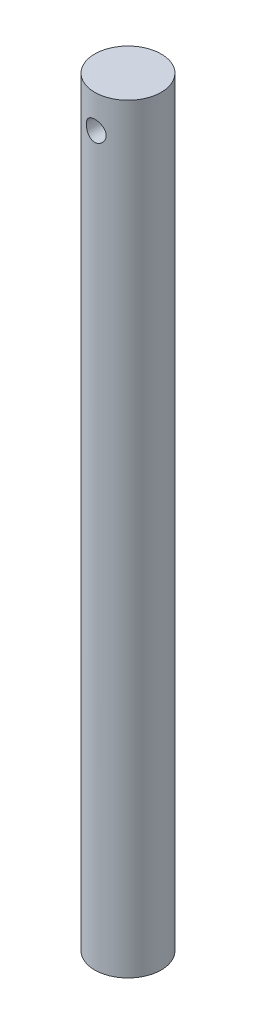
from build123d import *

# Parameters (mm, degrees)
SKETCH1_R               = 9.9949
BOSS_EXTRUDE1_DEPTH     = 228.6
SKETCH2_R               = 2.9972
CUT_EXTRUDE1_DEPTH      = 10.9949
CUT_EXTRUDE1_DEPTH_BACK = 10.9949


with BuildPart() as part:
    # Sketch1 → Boss-Extrude1 (new body)
    with BuildSketch(Plane(origin=(0, 0, 0), x_dir=(1, 0, 0), z_dir=(0, 1, 0))):
        Circle(SKETCH1_R)
    extrude(amount=BOSS_EXTRUDE1_DEPTH)

    # Sketch2 → Cut-Extrude1 (cut, two sides)
    with BuildSketch(Plane.XY) as cut_extrude1_sk:
        with Locations((0, 218.5924)):
            Circle(SKETCH2_R)
    extrude(amount=CUT_EXTRUDE1_DEPTH, mode=Mode.SUBTRACT)
    extrude(cut_extrude1_sk.sketch, amount=-CUT_EXTRUDE1_DEPTH_BACK, mode=Mode.SUBTRACT)


solid = part.part
